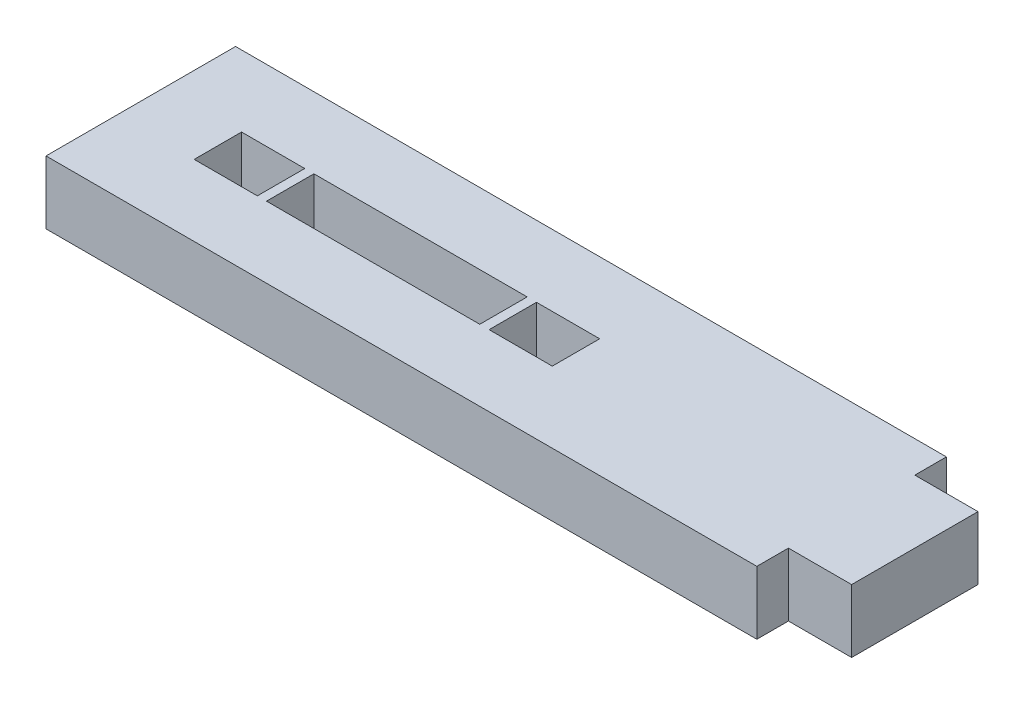
from build123d import *

# Parameters (mm, degrees)
SKETCH1_W               = 45
SKETCH1_H               = 12
BOSS_EXTRUDE1_DEPTH     = 4
SKETCH2_W               = 8
SKETCH2_H               = 8
BOSS_EXTRUDE2_DEPTH     = 4
SKETCH4_W               = 13.5
SKETCH4_H               = 3
CUT_EXTRUDE2_DEPTH      = 28.46361229
SKETCH4_3_W             = 4
SKETCH4_3_H             = 3
CUT_EXTRUDE_THIN2_DEPTH = 4
LPATTERN1_COUNT         = 2
LPATTERN1_PITCH         = 18.67


with BuildPart() as part:
    # Sketch1 → Boss-Extrude1 (new body)
    with BuildSketch(Plane(origin=(0, 0, 0), x_dir=(1, 0, 0), z_dir=(0, 1, 0))):
        Rectangle(SKETCH1_W, SKETCH1_H)
    extrude(amount=BOSS_EXTRUDE1_DEPTH)

    # Sketch2 → Boss-Extrude2 (add)
    with BuildSketch(Plane(origin=(0, 0, 0), x_dir=(1, 0, 0), z_dir=(0, 1, 0))):
        with Locations((22.5, 0)):
            Rectangle(SKETCH2_W, SKETCH2_H)
    extrude(amount=BOSS_EXTRUDE2_DEPTH)

    # Sketch4 → Cut-Extrude2 (cut, through all)
    with BuildSketch(Plane(origin=(0, 0, 0), x_dir=(1, 0, 0), z_dir=(0, 1, 0))):
        with Locations((-6.29, 0)):
            Rectangle(SKETCH4_W, SKETCH4_H)
    extrude(amount=CUT_EXTRUDE2_DEPTH, mode=Mode.SUBTRACT)

    # Sketch4_3 → Cut-Extrude-Thin2 (cut)
    with BuildSketch(Plane(origin=(0, 0, 0), x_dir=(1, 0, 0), z_dir=(0, 1, 0))):
        with Locations((3.05, 0)):
            Rectangle(SKETCH4_3_W, SKETCH4_3_H)
    cut_extrude_thin2 = extrude(amount=CUT_EXTRUDE_THIN2_DEPTH, mode=Mode.SUBTRACT)

    # LPattern1: Cut-Extrude-Thin2 ×2
    with Locations(*[(-i * LPATTERN1_PITCH, 0, 0) for i in range(1, LPATTERN1_COUNT)]):
        add(cut_extrude_thin2, mode=Mode.SUBTRACT)


solid = part.part
